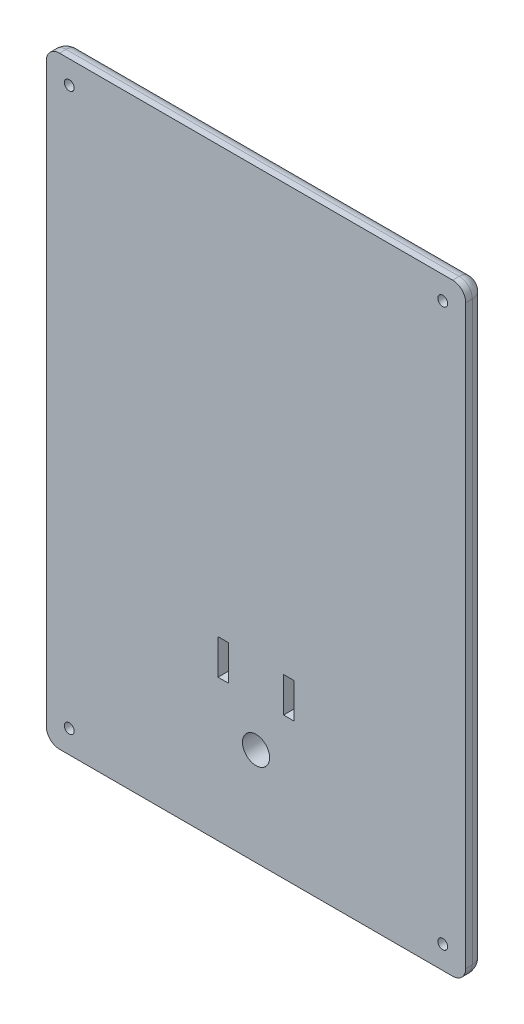
from build123d import *

# Parameters (mm, degrees)
SKETCH1_W           = 81.28
SKETCH1_H           = 116.84
BOSS_EXTRUDE1_DEPTH = 3.81
SKETCH6_R           = 2.6289
SKETCH6_W           = 2.032
SKETCH6_H           = 6.8072
CUT_EXTRUDE5_DEPTH  = 4.81
SKETCH7_R           = 0.9525
CUT_EXTRUDE6_DEPTH  = 4.81
FILLET1_R           = 2.54
CHAMFER1_SIZE       = 0.889
SKETCH2_W           = 38.071387925
SKETCH2_H           = 5.512590528
SKETCH2_H_2         = 5.504700738
CUT_EXTRUDE7_DEPTH  = 1.27
SKETCH10_W          = 0.75982906
SKETCH10_H          = 3.093589743
CUT_EXTRUDE8_DEPTH  = 1.905


with BuildPart() as part:
    # Sketch1 → Boss-Extrude1 (new body)
    with BuildSketch(Plane.XY):
        Rectangle(SKETCH1_W, SKETCH1_H)
    extrude(amount=BOSS_EXTRUDE1_DEPTH)

    # Sketch6 → Cut-Extrude5 (cut, through all)
    with BuildSketch(Plane.XY):
        with Locations((0, -39.497)):
            Circle(SKETCH6_R)
        with Locations((-6.35, -27.559)):
            Rectangle(SKETCH6_W, SKETCH6_H)
        with Locations((6.35, -27.559)):
            Rectangle(SKETCH6_W, SKETCH6_H)
    extrude(amount=CUT_EXTRUDE5_DEPTH, mode=Mode.SUBTRACT)

    # Sketch7 → Cut-Extrude6 (cut, through all)
    with BuildSketch(Plane.XY):
        with Locations((-36.195, 53.975)):
            Circle(SKETCH7_R)
        with Locations((-36.195, -53.975)):
            Circle(SKETCH7_R)
        with Locations((36.195, 53.975)):
            Circle(SKETCH7_R)
        with Locations((36.195, -53.975)):
            Circle(SKETCH7_R)
    extrude(amount=CUT_EXTRUDE6_DEPTH, mode=Mode.SUBTRACT)

    # Fillet1
    fillet1_edges = [part.edges().sort_by_distance(p)[0] for p in [
        (0, 58.42, 0),
        (40.64, 0, 0),
        (0, -58.42, 0),
        (-40.64, 0, 0),
        (-40.64, 58.42, 1.905),
        (40.64, 58.42, 1.905),
        (40.64, -58.42, 1.905),
        (-40.64, -58.42, 1.905),
    ]]
    fillet(fillet1_edges, radius=FILLET1_R)

    # Chamfer1
    chamfer1_edges = [part.edges().sort_by_distance(p)[0] for p in [
        (-37.1475, 53.975, 0),
        (-37.1475, -53.975, 0),
        (35.2425, 53.975, 0),
        (35.2425, -53.975, 0),
    ]]
    chamfer(chamfer1_edges, length=CHAMFER1_SIZE)

    # Sketch2 → Cut-Extrude7 (cut)
    with BuildSketch(Plane.XY):
        with Locations((-10.577370773, 4.552836284)):
            Rectangle(SKETCH2_W, SKETCH2_H)
        with Locations((-10.577370773, -2.752350369)):
            Rectangle(SKETCH2_W, SKETCH2_H_2)
    extrude(amount=CUT_EXTRUDE7_DEPTH, mode=Mode.SUBTRACT)

    # Sketch10 → Cut-Extrude8 (cut)
    with BuildSketch(Plane(origin=(0, 0, 0), x_dir=(-1, 0, 0), z_dir=(0, 0, -1))):
        with BuildLine():
            Line((-18.457038496, 6.289883896), (-19.025214244, 5.770045488))
            add(Edge.make_bspline(
                [(-19.025214244, 5.770045488), (-19.049552457, 5.804377067), (-19.096278431, 5.870288912), (-19.172016362, 5.958546425), (-19.247412298, 6.033836652), (-19.323164735, 6.095845065), (-19.399945115, 6.144194916), (-19.477620158, 6.178427145), (-19.555749502, 6.200188898), (-19.608240361, 6.20289876), (-19.63409512, 6.204233522)],
                knots=[0, 0, 0, 0, 0.000126193, 0.000242273, 0.000348412, 0.000445491, 0.000535382, 0.000619678, 0.000699487, 0.000776955, 0.000776955, 0.000776955, 0.000776955], degree=3))
            add(Edge.make_bspline(
                [(-19.63409512, 6.204233522), (-19.658211698, 6.203387756), (-19.704774473, 6.201754802), (-19.771153162, 6.185523369), (-19.830085109, 6.157510299), (-19.881512796, 6.120880853), (-19.922251112, 6.076750863), (-19.954777498, 6.03046985), (-19.973092587, 5.979386078), (-19.975503213, 5.944299683), (-19.976696616, 5.926929836)],
                knots=[0, 0, 0, 0, 7.2261e-05, 0.000139518, 0.000203249, 0.000267032, 0.000327622, 0.000382659, 0.000435767, 0.000487836, 0.000487836, 0.000487836, 0.000487836], degree=3))
            add(Edge.make_bspline(
                [(-19.976696616, 5.926929836), (-19.975948771, 5.909309509), (-19.974442715, 5.873824617), (-19.959896263, 5.821817089), (-19.937970607, 5.770999681), (-19.917019747, 5.740064706), (-19.906310665, 5.724252219)],
                knots=[0, 0, 0, 0, 5.2748e-05, 0.000106227, 0.000160904, 0.000218074, 0.000218074, 0.000218074, 0.000218074], degree=3))
            add(Edge.make_bspline(
                [(-19.906310665, 5.724252219), (-19.896574951, 5.711961338), (-19.874164622, 5.683669354), (-19.831432716, 5.638859262), (-19.777770415, 5.583962977), (-19.711112683, 5.52086822), (-19.634226664, 5.447305859), (-19.543548594, 5.366167658), (-19.441688581, 5.27494086), (-19.369288843, 5.211413822), (-19.331350729, 5.178125082)],
                knots=[0, 0, 0, 0, 4.7018e-05, 0.000108228, 0.000185584, 0.000277347, 0.000383527, 0.000504803, 0.000642342, 0.000793757, 0.000793757, 0.000793757, 0.000793757], degree=3))
            add(Edge.make_bspline(
                [(-19.331350729, 5.178125082), (-19.295740352, 5.147306097), (-19.228159254, 5.088818066), (-19.132004773, 5.005803696), (-19.047500998, 4.931117692), (-18.973416902, 4.86588093), (-18.910875529, 4.809408928), (-18.859613953, 4.76143175), (-18.819006103, 4.722883424), (-18.795922917, 4.699600211), (-18.786071616, 4.689663544)],
                knots=[0, 0, 0, 0, 0.000141284, 0.000268128, 0.000381091, 0.000479615, 0.000564269, 0.000633869, 0.000690248, 0.000732223, 0.000732223, 0.000732223, 0.000732223], degree=3))
            add(Edge.make_bspline(
                [(-18.786071616, 4.689663544), (-18.748697833, 4.649217106), (-18.676852297, 4.571464849), (-18.583478427, 4.450973302), (-18.506628711, 4.333348985), (-18.447176314, 4.216378603), (-18.402275473, 4.098374507), (-18.370619785, 3.976442654), (-18.351660983, 3.849308931), (-18.349556113, 3.762555686), (-18.348491488, 3.718676631)],
                knots=[0, 0, 0, 0, 0.000165147, 0.000317471, 0.000456725, 0.00058605, 0.000710317, 0.000834757, 0.000963321, 0.001094899, 0.001094899, 0.001094899, 0.001094899], degree=3))
            add(Edge.make_bspline(
                [(-18.348491488, 3.718676631), (-18.349249261, 3.675921874), (-18.35073604, 3.592035449), (-18.368946228, 3.469280161), (-18.394912888, 3.351798023), (-18.4350619, 3.240867406), (-18.483995277, 3.134667418), (-18.545340334, 3.034852318), (-18.617381691, 2.940411936), (-18.699952147, 2.853034509), (-18.791284877, 2.77374555), (-18.889247909, 2.703160646), (-18.994799177, 2.644883816), (-19.107036866, 2.596897005), (-19.225900898, 2.55993692), (-19.35124967, 2.532619973), (-19.483274913, 2.516224772), (-19.573555676, 2.514510849), (-19.619678721, 2.513635232)],
                knots=[0, 0, 0, 0, 0.000128153, 0.00025144, 0.000371573, 0.000488514, 0.000604603, 0.000721827, 0.000839198, 0.000960379, 0.001081798, 0.001201573, 0.001321912, 0.001442728, 0.001567176, 0.001694755, 0.001827183, 0.001965504, 0.001965504, 0.001965504, 0.001965504], degree=3))
            add(Edge.make_bspline(
                [(-19.619678721, 2.513635232), (-19.655884918, 2.514277554), (-19.727593954, 2.51554972), (-19.83328223, 2.525935897), (-19.935336209, 2.542698081), (-20.033640935, 2.566723299), (-20.128639288, 2.597166509), (-20.22033517, 2.634351723), (-20.308095574, 2.678855298), (-20.392584536, 2.729762065), (-20.473391336, 2.788871527), (-20.551537744, 2.85497521), (-20.626247536, 2.929089819), (-20.697879527, 3.011040076), (-20.765975397, 3.101058044), (-20.832764167, 3.197890055), (-20.895277543, 3.303333182), (-20.933894837, 3.377302388), (-20.953619693, 3.415084217)],
                knots=[0, 0, 0, 0, 0.0001086, 0.00021509, 0.000318257, 0.000418629, 0.000518393, 0.000617289, 0.000715135, 0.000813305, 0.000912874, 0.001015159, 0.001120098, 0.001228274, 0.001341404, 0.001458542, 0.001580999, 0.001708851, 0.001708851, 0.001708851, 0.001708851], degree=3))
            Line((-20.953619693, 3.415084217), (-20.285377172, 3.816199334))
            add(Edge.make_bspline(
                [(-20.285377172, 3.816199334), (-20.260704324, 3.773312022), (-20.213404368, 3.69109338), (-20.133250169, 3.580622213), (-20.051136285, 3.486021946), (-19.965164315, 3.408964642), (-19.876379647, 3.348419948), (-19.78435343, 3.30515051), (-19.689021009, 3.278366776), (-19.624084894, 3.275095864), (-19.591693945, 3.273464291)],
                knots=[0, 0, 0, 0, 0.000148344, 0.000284387, 0.000408758, 0.00052348, 0.000629791, 0.000729947, 0.000827455, 0.000924501, 0.000924501, 0.000924501, 0.000924501], degree=3))
            add(Edge.make_bspline(
                [(-19.591693945, 3.273464291), (-19.558747713, 3.274796722), (-19.494827224, 3.277381831), (-19.403588905, 3.301259702), (-19.31993816, 3.338749712), (-19.247631074, 3.392242786), (-19.186405993, 3.453981923), (-19.141218368, 3.522669537), (-19.112831198, 3.596987877), (-19.109829985, 3.648614284), (-19.108320548, 3.674579409)],
                knots=[0, 0, 0, 0, 9.8666e-05, 0.000191427, 0.000280981, 0.000372071, 0.000459628, 0.000540542, 0.000617268, 0.000694903, 0.000694903, 0.000694903, 0.000694903], degree=3))
            add(Edge.make_bspline(
                [(-19.108320548, 3.674579409), (-19.109714452, 3.698735732), (-19.112546034, 3.74780699), (-19.133402598, 3.82076806), (-19.166007769, 3.893695949), (-19.204581985, 3.953513376), (-19.243836081, 4.003596887), (-19.28137185, 4.046991983), (-19.327080487, 4.094935968), (-19.380846096, 4.14748915), (-19.441958291, 4.205114169), (-19.510468554, 4.267805382), (-19.587161397, 4.335010555), (-19.64136805, 4.380790054), (-19.669712107, 4.404727646)],
                knots=[0, 0, 0, 0, 7.2401e-05, 0.000147075, 0.000226032, 0.00031143, 0.000359775, 0.000416896, 0.00048348, 0.000558438, 0.000642422, 0.000735462, 0.000837016, 0.000948314, 0.000948314, 0.000948314, 0.000948314], degree=3))
            add(Edge.make_bspline(
                [(-19.669712107, 4.404727646), (-19.723595288, 4.450317984), (-19.827013421, 4.537819641), (-19.973156364, 4.667056835), (-20.104844241, 4.787840834), (-20.220939654, 4.901664794), (-20.322921838, 5.006426648), (-20.410100126, 5.102977314), (-20.481516825, 5.192061547), (-20.556667501, 5.297575859), (-20.628075669, 5.426152299), (-20.689792589, 5.580844662), (-20.729831923, 5.735517396), (-20.734317773, 5.839356151), (-20.736525676, 5.890464826)],
                knots=[0, 0, 0, 0, 0.000211741, 0.000406395, 0.000585234, 0.000747747, 0.00089408, 0.001023802, 0.001137832, 0.001236415, 0.001412187, 0.001577378, 0.00173534, 0.001888445, 0.001888445, 0.001888445, 0.001888445], degree=3))
            add(Edge.make_bspline(
                [(-20.736525676, 5.890464826), (-20.735607412, 5.926708355), (-20.733798334, 5.998112), (-20.717661076, 6.103100657), (-20.693543329, 6.204405889), (-20.658517437, 6.301658089), (-20.613058059, 6.394735444), (-20.557849409, 6.484093608), (-20.492034203, 6.568910148), (-20.417864908, 6.649128837), (-20.336149335, 6.72243959), (-20.248825861, 6.787143675), (-20.156388744, 6.841793686), (-20.059403468, 6.887129838), (-19.957269055, 6.921831783), (-19.850737926, 6.946430251), (-19.739657279, 6.961060635), (-19.664102621, 6.963049466), (-19.625614885, 6.964062582)],
                knots=[0, 0, 0, 0, 0.000108666, 0.000214084, 0.000317952, 0.000420689, 0.000523472, 0.000628195, 0.000735224, 0.000845039, 0.000955536, 0.001064086, 0.001170546, 0.001277158, 0.001384697, 0.001493515, 0.001604697, 0.00172014, 0.00172014, 0.00172014, 0.00172014], degree=3))
            add(Edge.make_bspline(
                [(-19.625614885, 6.964062582), (-19.575736684, 6.962237931), (-19.476374004, 6.958603033), (-19.329463414, 6.930179314), (-19.185967293, 6.885480022), (-19.070335429, 6.831555244), (-18.978329314, 6.779318286), (-18.907815221, 6.731225075), (-18.836063335, 6.676131717), (-18.762495024, 6.613864599), (-18.688477298, 6.543250525), (-18.611905482, 6.46597052), (-18.533822958, 6.381356704), (-18.483081698, 6.320908986), (-18.457038496, 6.289883896)],
                knots=[0, 0, 0, 0, 0.000149543, 0.000297906, 0.000447296, 0.000599454, 0.000679604, 0.000764513, 0.000855255, 0.000950917, 0.001053499, 0.001162036, 0.001277268, 0.001398775, 0.001398775, 0.001398775, 0.001398775], degree=3))
        make_face()
        Polygon((-17.968576958, 1.86235318), (-16.020666969, 6.964062582), (-15.444859009, 6.964062582), (-17.392768998, 1.86235318), align=None)
        Polygon((-14.874987214, 6.855515574), (-14.190632246, 6.855515574), (-12.269859009, 4.069758362), (-12.269859009, 6.855515574), (-11.510029949, 6.855515574), (-11.510029949, 2.62218224), (-12.199473058, 2.62218224), (-14.115158154, 5.399459217), (-14.115158154, 2.62218224), (-14.874987214, 2.62218224), align=None)
        with BuildLine():
            add(Edge.make_bspline(
                [(-10.234602599, 5.770045488), (-10.203900167, 5.768457699), (-10.143373019, 5.765327514), (-10.056460869, 5.739217177), (-9.977251147, 5.695225129), (-9.907087465, 5.636251514), (-9.847818666, 5.565938911), (-9.804323015, 5.486178341), (-9.777873854, 5.398849173), (-9.77482918, 5.33801949), (-9.773277813, 5.307024655)],
                knots=[0, 0, 0, 0, 9.1978e-05, 0.000181327, 0.000269379, 0.000362105, 0.00045483, 0.000543626, 0.000632975, 0.000725798, 0.000725798, 0.000725798, 0.000725798], degree=3))
            add(Edge.make_bspline(
                [(-9.773277813, 5.307024655), (-9.774808913, 5.276582237), (-9.777813831, 5.216836345), (-9.804714785, 5.130822537), (-9.847781664, 5.051491801), (-9.907097577, 4.981192811), (-9.977248591, 4.922215536), (-10.056461545, 4.878224422), (-10.143372843, 4.852113839), (-10.203900108, 4.848983687), (-10.234602599, 4.847395915)],
                knots=[0, 0, 0, 0, 9.1134e-05, 0.000178858, 0.000267654, 0.00036038, 0.000453106, 0.000541157, 0.000630506, 0.000722485, 0.000722485, 0.000722485, 0.000722485], degree=3))
            add(Edge.make_bspline(
                [(-10.234602599, 4.847395915), (-10.265320939, 4.848953623), (-10.32587945, 4.852024507), (-10.412672804, 4.878601514), (-10.492678222, 4.920952215), (-10.562799548, 4.979563839), (-10.622657842, 5.048794947), (-10.664462323, 5.128779592), (-10.691516568, 5.21540277), (-10.694434127, 5.276006561), (-10.695927385, 5.307024655)],
                knots=[0, 0, 0, 0, 9.1978e-05, 0.000181327, 0.000269721, 0.000361906, 0.000453982, 0.000542376, 0.000630913, 0.000723735, 0.000723735, 0.000723735, 0.000723735], degree=3))
            add(Edge.make_bspline(
                [(-10.695927385, 5.307024655), (-10.694396688, 5.338030788), (-10.691392582, 5.398882645), (-10.664688146, 5.485921351), (-10.622411939, 5.566190848), (-10.562876564, 5.636179344), (-10.492695641, 5.695518905), (-10.412901025, 5.738997043), (-10.325853802, 5.765365886), (-10.265312308, 5.768470613), (-10.234602599, 5.770045488)],
                knots=[0, 0, 0, 0, 9.2823e-05, 0.000182172, 0.000270566, 0.000363291, 0.000456017, 0.000544813, 0.000634162, 0.00072614, 0.00072614, 0.00072614, 0.00072614], degree=3))
        make_face()
        with BuildLine():
            add(Edge.make_bspline(
                [(-10.234602599, 3.490558309), (-10.203929201, 3.48887656), (-10.143538577, 3.485565487), (-10.05628236, 3.460855297), (-9.977533122, 3.416459921), (-9.907120781, 3.358553846), (-9.847581878, 3.288885108), (-9.804548506, 3.20943643), (-9.777750546, 3.122516423), (-9.774792032, 3.061935803), (-9.773277813, 3.030929569)],
                knots=[0, 0, 0, 0, 9.1978e-05, 0.000181089, 0.000269141, 0.000361326, 0.000453402, 0.000542198, 0.000630734, 0.000723557, 0.000723557, 0.000723557, 0.000723557], degree=3))
            add(Edge.make_bspline(
                [(-9.773277813, 3.030929569), (-9.774782113, 2.999918356), (-9.777721245, 2.939328006), (-9.804733945, 2.85223863), (-9.847517573, 2.772136956), (-9.907125558, 2.701721671), (-9.97724152, 2.642724303), (-10.056463418, 2.598738316), (-10.143372356, 2.57262638), (-10.203899944, 2.569496413), (-10.234602599, 2.567908736)],
                knots=[0, 0, 0, 0, 9.2823e-05, 0.000181359, 0.000270901, 0.000363627, 0.000456353, 0.000544404, 0.000633753, 0.000725731, 0.000725731, 0.000725731, 0.000725731], degree=3))
            add(Edge.make_bspline(
                [(-10.234602599, 2.567908736), (-10.265312529, 2.569483503), (-10.325854459, 2.572588018), (-10.41289849, 2.598958414), (-10.492705266, 2.642430635), (-10.562838845, 2.701793235), (-10.622713132, 2.771887609), (-10.664280382, 2.852491365), (-10.691544698, 2.939295172), (-10.69444365, 2.99990724), (-10.695927385, 3.030929569)],
                knots=[0, 0, 0, 0, 9.1978e-05, 0.000181327, 0.000270123, 0.000362849, 0.000455575, 0.000544718, 0.000633254, 0.000726077, 0.000726077, 0.000726077, 0.000726077], degree=3))
            add(Edge.make_bspline(
                [(-10.695927385, 3.030929569), (-10.694433861, 3.061947112), (-10.691515783, 3.122549828), (-10.664465293, 3.209180783), (-10.622646513, 3.289135809), (-10.562843839, 3.358482134), (-10.492412162, 3.416751296), (-10.413080564, 3.460638215), (-10.325688321, 3.485604133), (-10.265283307, 3.488889577), (-10.234602599, 3.490558309)],
                knots=[0, 0, 0, 0, 9.2823e-05, 0.000181359, 0.000269753, 0.000361829, 0.000454014, 0.00054281, 0.000631921, 0.000723899, 0.000723899, 0.000723899, 0.000723899], degree=3))
        make_face()
        Polygon((-36.207374758, -0.250875626), (-34.144981596, -0.250875626), (-34.144981596, -1.010704686), (-35.447545698, -1.010704686), (-35.447545698, -1.82480725), (-34.144981596, -1.82480725), (-34.144981596, -2.58463631), (-35.447545698, -2.58463631), (-35.447545698, -4.484208959), (-36.207374758, -4.484208959), align=None)
        with BuildLine():
            add(Edge.make_bspline(
                [(-33.169754566, -0.088055113), (-33.137005938, -0.089661885), (-33.072700854, -0.092816935), (-32.98057507, -0.123571663), (-32.89602227, -0.171840288), (-32.821275251, -0.238065992), (-32.75910767, -0.317151597), (-32.711609329, -0.405693189), (-32.685149982, -0.503794421), (-32.68147517, -0.571561726), (-32.67959698, -0.606197474)],
                knots=[0, 0, 0, 0, 9.7968e-05, 0.000192369, 0.000288087, 0.000388444, 0.000489896, 0.000588518, 0.000687886, 0.000791764, 0.000791764, 0.000791764, 0.000791764], degree=3))
            add(Edge.make_bspline(
                [(-32.67959698, -0.606197474), (-32.681407972, -0.640577976), (-32.684936774, -0.707570021), (-32.712218307, -0.804339483), (-32.75781023, -0.89283807), (-32.820481329, -0.970749107), (-32.894417993, -1.035908207), (-32.977123249, -1.08505312), (-33.068366201, -1.114096969), (-33.131673465, -1.117515764), (-33.163818401, -1.119251694)],
                knots=[0, 0, 0, 0, 0.000103034, 0.000200767, 0.000298998, 0.000399785, 0.000498946, 0.000593194, 0.000686531, 0.000782811, 0.000782811, 0.000782811, 0.000782811], degree=3))
            add(Edge.make_bspline(
                [(-33.163818401, -1.119251694), (-33.196852897, -1.117650666), (-33.261717433, -1.114506985), (-33.354598838, -1.083680299), (-33.440279356, -1.035791821), (-33.514702123, -0.968213022), (-33.577581662, -0.888565455), (-33.623005257, -0.797962538), (-33.651418839, -0.699190492), (-33.654791506, -0.630419507), (-33.656520057, -0.595173168)],
                knots=[0, 0, 0, 0, 9.8812e-05, 0.000194021, 0.000290476, 0.000391395, 0.000493514, 0.000593257, 0.000693668, 0.000799236, 0.000799236, 0.000799236, 0.000799236], degree=3))
            add(Edge.make_bspline(
                [(-33.656520057, -0.595173168), (-33.654638921, -0.561376468), (-33.6509437, -0.494987729), (-33.624325859, -0.399067575), (-33.577916653, -0.312014505), (-33.516196871, -0.234376637), (-33.442106382, -0.169386291), (-33.357604341, -0.122583616), (-33.266098567, -0.093099146), (-33.202200832, -0.089753818), (-33.169754566, -0.088055113)],
                knots=[0, 0, 0, 0, 0.000101345, 0.000199078, 0.000295804, 0.000395399, 0.0004952, 0.000589346, 0.000683492, 0.000780615, 0.000780615, 0.000780615, 0.000780615], degree=3))
        make_face()
        with Locations((-33.168058519, -2.937414088)):
            Rectangle(SKETCH10_W, SKETCH10_H)
        with BuildLine():
            Line((-32.191135442, -1.390619216), (-31.53985339, -1.390619216))
            Line((-31.53985339, -1.390619216), (-31.53985339, -1.771381769))
            add(Edge.make_bspline(
                [(-31.53985339, -1.771381769), (-31.521429872, -1.737543296), (-31.485420339, -1.671404597), (-31.419267809, -1.582626491), (-31.343269102, -1.507860047), (-31.260155089, -1.445541457), (-31.169673865, -1.396970235), (-31.074248358, -1.362357117), (-30.974694931, -1.339863386), (-30.906782958, -1.337526712), (-30.872458893, -1.336345711)],
                knots=[0, 0, 0, 0, 0.000115493, 0.000225736, 0.000330676, 0.000434305, 0.000536367, 0.00063751, 0.000738139, 0.000840974, 0.000840974, 0.000840974, 0.000840974], degree=3))
            add(Edge.make_bspline(
                [(-30.872458893, -1.336345711), (-30.847535338, -1.337512787), (-30.796782082, -1.339889371), (-30.719426977, -1.353704486), (-30.640955775, -1.378684843), (-30.589314961, -1.401176333), (-30.562930314, -1.412667827)],
                knots=[0, 0, 0, 0, 7.4799e-05, 0.000152318, 0.00023493, 0.000321233, 0.000321233, 0.000321233, 0.000321233], degree=3))
            Line((-30.562930314, -1.412667827), (-30.798680848, -2.056317666))
            add(Edge.make_bspline(
                [(-30.798680848, -2.056317666), (-30.819753579, -2.046136341), (-30.859362202, -2.02699937), (-30.916867044, -2.004415772), (-30.969055074, -1.990636365), (-31.002141326, -1.988580356), (-31.017470912, -1.987627763)],
                knots=[0, 0, 0, 0, 7.0186e-05, 0.000131923, 0.000185194, 0.000231183, 0.000231183, 0.000231183, 0.000231183], degree=3))
            add(Edge.make_bspline(
                [(-31.017470912, -1.987627763), (-31.031945022, -1.988259001), (-31.06041809, -1.989500757), (-31.102443542, -2.000142182), (-31.142022767, -2.01849299), (-31.181063085, -2.042002195), (-31.216484647, -2.074681749), (-31.251884331, -2.112514135), (-31.283080427, -2.159223248), (-31.316001356, -2.211212863), (-31.34403235, -2.274848105), (-31.368068065, -2.35081547), (-31.389484079, -2.439993953), (-31.404221221, -2.542857047), (-31.41846526, -2.658409376), (-31.426943662, -2.787499078), (-31.433262722, -2.92971796), (-31.43364909, -3.028991873), (-31.433850452, -3.08073006)],
                knots=[0, 0, 0, 0, 4.3382e-05, 8.534e-05, 0.000128995, 0.00017394, 0.000221406, 0.000273031, 0.000329027, 0.000389528, 0.000457466, 0.000536845, 0.000628377, 0.000732245, 0.000848372, 0.000977608, 0.0011202, 0.001275397, 0.001275397, 0.001275397, 0.001275397], degree=3))
            Line((-31.433850452, -3.08073006), (-31.431306382, -3.231678243))
            Line((-31.431306382, -3.231678243), (-31.431306382, -4.484208959))
            Line((-31.431306382, -4.484208959), (-32.191135442, -4.484208959))
            Line((-32.191135442, -4.484208959), (-32.191135442, -1.390619216))
        make_face()
        with BuildLine():
            Line((-30.183015784, -1.390619216), (-29.423186724, -1.390619216))
            Line((-29.423186724, -1.390619216), (-29.423186724, -1.760357463))
            add(Edge.make_bspline(
                [(-29.423186724, -1.760357463), (-29.389389913, -1.726246769), (-29.322846771, -1.659085616), (-29.212571768, -1.572743916), (-29.097543773, -1.498911096), (-28.976368829, -1.439138781), (-28.849343327, -1.393498301), (-28.717069299, -1.360053631), (-28.578867332, -1.340322323), (-28.484770472, -1.337685942), (-28.436935388, -1.336345711)],
                knots=[0, 0, 0, 0, 0.000143934, 0.000283395, 0.000419134, 0.00055339, 0.000687788, 0.000823328, 0.000962086, 0.001105562, 0.001105562, 0.001105562, 0.001105562], degree=3))
            add(Edge.make_bspline(
                [(-28.436935388, -1.336345711), (-28.389037146, -1.337852324), (-28.294751004, -1.340818043), (-28.15718818, -1.367957152), (-28.026869382, -1.412049032), (-27.905228425, -1.474896591), (-27.791386158, -1.552510058), (-27.690385869, -1.648899191), (-27.599473472, -1.760226948), (-27.551013664, -1.844391929), (-27.526158145, -1.887560989)],
                knots=[0, 0, 0, 0, 0.000143567, 0.000282606, 0.00041884, 0.000554995, 0.000692136, 0.000830717, 0.000972429, 0.001121652, 0.001121652, 0.001121652, 0.001121652], degree=3))
            add(Edge.make_bspline(
                [(-27.526158145, -1.887560989), (-27.494141024, -1.844274493), (-27.4313004, -1.759315248), (-27.31990967, -1.648391322), (-27.199463058, -1.552500007), (-27.067630199, -1.474323593), (-26.927912116, -1.412263552), (-26.780920198, -1.368120977), (-26.627987124, -1.3408634), (-26.523907774, -1.337864118), (-26.471216905, -1.336345711)],
                knots=[0, 0, 0, 0, 0.000161323, 0.000316632, 0.00047, 0.000622125, 0.000775131, 0.000927512, 0.001081567, 0.001239528, 0.001239528, 0.001239528, 0.001239528], degree=3))
            add(Edge.make_bspline(
                [(-26.471216905, -1.336345711), (-26.416793495, -1.337922343), (-26.310808963, -1.340992685), (-26.157222157, -1.371199484), (-26.013369528, -1.41787352), (-25.882430178, -1.485795666), (-25.764030656, -1.566252137), (-25.66313998, -1.661314816), (-25.579409938, -1.767666558), (-25.524890943, -1.866973136), (-25.489645878, -1.954771523), (-25.468364594, -2.03117257), (-25.44846001, -2.116484003), (-25.434160558, -2.211852526), (-25.42081265, -2.31638175), (-25.413063665, -2.430766619), (-25.407796599, -2.554621798), (-25.40723717, -2.640316522), (-25.406947408, -2.684703083)],
                knots=[0, 0, 0, 0, 0.000163088, 0.000317598, 0.000467772, 0.000615304, 0.00075856, 0.000895942, 0.001029449, 0.001163049, 0.001234228, 0.001312856, 0.0014007, 0.001496897, 0.001601977, 0.001716773, 0.001840689, 0.00197384, 0.00197384, 0.00197384, 0.00197384], degree=3))
            Line((-25.406947408, -2.684703083), (-25.406947408, -4.484208959))
            Line((-25.406947408, -4.484208959), (-26.166776467, -4.484208959))
            Line((-26.166776467, -4.484208959), (-26.166776467, -2.930629899))
            add(Edge.make_bspline(
                [(-26.166776467, -2.930629899), (-26.167408881, -2.889074547), (-26.168622742, -2.809312804), (-26.173783333, -2.694909812), (-26.185334944, -2.59115617), (-26.198874912, -2.497477181), (-26.218250867, -2.414369541), (-26.241876326, -2.34163291), (-26.269281715, -2.279162584), (-26.302372896, -2.226965075), (-26.339435058, -2.183006528), (-26.380661366, -2.145325348), (-26.425621974, -2.113175845), (-26.474724516, -2.085772962), (-26.529255351, -2.06723985), (-26.587373605, -2.052698109), (-26.649534072, -2.04279508), (-26.692511804, -2.04220469), (-26.714599651, -2.041901267)],
                knots=[0, 0, 0, 0, 0.000124685, 0.000239322, 0.000343367, 0.000437757, 0.000523121, 0.000599014, 0.000666951, 0.000727178, 0.000783749, 0.000838968, 0.000894272, 0.000949295, 0.001006967, 0.001066408, 0.001129012, 0.001195207, 0.001195207, 0.001195207, 0.001195207], degree=3))
            add(Edge.make_bspline(
                [(-26.714599651, -2.041901267), (-26.748636711, -2.043078016), (-26.815427668, -2.045387153), (-26.912755704, -2.067453538), (-27.004342104, -2.103529715), (-27.089843747, -2.152608159), (-27.167420826, -2.213906209), (-27.235281133, -2.286611541), (-27.291324283, -2.371143161), (-27.330118717, -2.449571549), (-27.354360366, -2.520486571), (-27.371460645, -2.581219592), (-27.384789634, -2.649899656), (-27.395222329, -2.725831192), (-27.405231282, -2.809443448), (-27.410141618, -2.900630695), (-27.41516639, -2.999266252), (-27.415100978, -3.067436111), (-27.415067066, -3.102778671)],
                knots=[0, 0, 0, 0, 0.000101989, 0.000200133, 0.000297611, 0.000396379, 0.000494783, 0.00059319, 0.000693386, 0.000798065, 0.000854654, 0.000918024, 0.000987209, 0.001064323, 0.001147951, 0.00123973, 0.001338192, 0.001444199, 0.001444199, 0.001444199, 0.001444199], degree=3))
            Line((-27.415067066, -3.102778671), (-27.415067066, -4.484208959))
            Line((-27.415067066, -4.484208959), (-28.174896126, -4.484208959))
            Line((-28.174896126, -4.484208959), (-28.174896126, -3.00101585))
            add(Edge.make_bspline(
                [(-28.174896126, -3.00101585), (-28.174959921, -2.967938691), (-28.175082643, -2.904308951), (-28.178771415, -2.812426389), (-28.183656071, -2.727585443), (-28.19050379, -2.649549477), (-28.198401284, -2.578415549), (-28.209799189, -2.51457281), (-28.22177374, -2.457669469), (-28.242304269, -2.39302897), (-28.271234425, -2.32139648), (-28.314456501, -2.245434213), (-28.366717893, -2.181833716), (-28.426697699, -2.130100043), (-28.494477454, -2.090683135), (-28.568340085, -2.061361854), (-28.649695953, -2.045535127), (-28.705695893, -2.043138115), (-28.734591638, -2.041901267)],
                knots=[0, 0, 0, 0, 9.9222e-05, 0.000190872, 0.000275827, 0.000354139, 0.000425876, 0.000490426, 0.00054865, 0.00060015, 0.000693694, 0.000779947, 0.000861273, 0.000939457, 0.001016249, 0.001095461, 0.001176787, 0.001263489, 0.001263489, 0.001263489, 0.001263489], degree=3))
            add(Edge.make_bspline(
                [(-28.734591638, -2.041901267), (-28.767241344, -2.043009454), (-28.831904359, -2.045204229), (-28.926095918, -2.068777905), (-29.016151785, -2.104192152), (-29.10009082, -2.154639468), (-29.176499196, -2.217380048), (-29.243680077, -2.292153421), (-29.299428699, -2.378870895), (-29.338395334, -2.459462619), (-29.36228351, -2.532146873), (-29.379843592, -2.594456884), (-29.392676657, -2.664649437), (-29.403383868, -2.741936395), (-29.413333564, -2.826408985), (-29.418264218, -2.918438685), (-29.423284025, -3.017923489), (-29.423219939, -3.086658138), (-29.423186724, -3.122283211)],
                knots=[0, 0, 0, 0, 9.7758e-05, 0.000193611, 0.000289513, 0.000387246, 0.000486054, 0.000585142, 0.000687458, 0.00079443, 0.000852624, 0.000916811, 0.000988492, 0.001066446, 0.001150917, 0.001243542, 0.001342851, 0.001449706, 0.001449706, 0.001449706, 0.001449706], degree=3))
            Line((-29.423186724, -3.122283211), (-29.423186724, -4.484208959))
            Line((-29.423186724, -4.484208959), (-30.183015784, -4.484208959))
            Line((-30.183015784, -4.484208959), (-30.183015784, -1.390619216))
        make_face()
        Polygon((-24.999896126, -1.390619216), (-24.241763113, -1.390619216), (-23.588785014, -3.150267987), (-22.897645858, -1.390619216), (-22.432080955, -1.390619216), (-21.743485869, -3.130763446), (-21.093051841, -1.390619216), (-20.332374758, -1.390619216), (-21.489078818, -4.484208959), (-21.968212098, -4.484208959), (-22.666135442, -2.721168094), (-23.358970645, -4.484208959), (-23.852520324, -4.484208959), align=None)
        with BuildLine():
            Line((-17.645836296, -1.390619216), (-16.886007237, -1.390619216))
            Line((-16.886007237, -1.390619216), (-16.886007237, -4.484208959))
            Line((-16.886007237, -4.484208959), (-17.645836296, -4.484208959))
            Line((-17.645836296, -4.484208959), (-17.645836296, -4.146695604))
            add(Edge.make_bspline(
                [(-17.645836296, -4.146695604), (-17.683485546, -4.179548794), (-17.756555306, -4.243310347), (-17.871689602, -4.326042584), (-17.987160334, -4.394285986), (-18.103522342, -4.448638135), (-18.222564061, -4.488771602), (-18.345142544, -4.51782917), (-18.473023051, -4.534965128), (-18.559954458, -4.537297806), (-18.604102856, -4.538482463)],
                knots=[0, 0, 0, 0, 0.000149841, 0.000290812, 0.000424617, 0.000551722, 0.00067535, 0.000800823, 0.000929153, 0.001061577, 0.001061577, 0.001061577, 0.001061577], degree=3))
            add(Edge.make_bspline(
                [(-18.604102856, -4.538482463), (-18.653661396, -4.537367551), (-18.75159188, -4.535164422), (-18.895293993, -4.511972928), (-19.03405267, -4.476473178), (-19.167755277, -4.426236595), (-19.296158554, -4.361139831), (-19.420245175, -4.282881353), (-19.537887919, -4.18871382), (-19.65006612, -4.082711621), (-19.752775809, -3.966108447), (-19.842565588, -3.840522736), (-19.918251698, -3.707735642), (-19.980257279, -3.568187417), (-20.029032675, -3.42198048), (-20.063802553, -3.268651109), (-20.084316821, -3.108144541), (-20.086855909, -2.998813752), (-20.088143989, -2.943350252)],
                knots=[0, 0, 0, 0, 0.000148559, 0.000293561, 0.000435483, 0.000577713, 0.00072107, 0.000866695, 0.001017016, 0.00117238, 0.001329218, 0.001482413, 0.00163472, 0.001786951, 0.001939807, 0.002096361, 0.002257925, 0.002424276, 0.002424276, 0.002424276, 0.002424276], degree=3))
            add(Edge.make_bspline(
                [(-20.088143989, -2.943350252), (-20.086792145, -2.885917724), (-20.084140352, -2.773257422), (-20.064742646, -2.607933785), (-20.030614403, -2.450802624), (-19.984078091, -2.301646291), (-19.924217205, -2.160439015), (-19.851310647, -2.026949456), (-19.764366589, -1.901526533), (-19.664178976, -1.786305033), (-19.556000961, -1.680698963), (-19.440269609, -1.588760504), (-19.318794705, -1.510654505), (-19.191447161, -1.446889699), (-19.058245164, -1.397615484), (-18.919714591, -1.36159201), (-18.775240466, -1.33997666), (-18.676823521, -1.337566079), (-18.626999491, -1.336345711)],
                knots=[0, 0, 0, 0, 0.000172282, 0.000337951, 0.000498461, 0.000654022, 0.000806017, 0.000957822, 0.001109552, 0.001262885, 0.001415213, 0.001562486, 0.001705511, 0.001847729, 0.001988868, 0.00213079, 0.002276504, 0.002425911, 0.002425911, 0.002425911, 0.002425911], degree=3))
            add(Edge.make_bspline(
                [(-18.626999491, -1.336345711), (-18.580846295, -1.337304554), (-18.489525756, -1.339201757), (-18.355297722, -1.359801754), (-18.225115888, -1.390957787), (-18.099690403, -1.435349525), (-17.977992486, -1.491403126), (-17.862115418, -1.561642467), (-17.749524283, -1.643115418), (-17.680825987, -1.706747519), (-17.645836296, -1.739156876)],
                knots=[0, 0, 0, 0, 0.000138355, 0.000273755, 0.000406419, 0.000539448, 0.000672238, 0.000807638, 0.000945366, 0.001088328, 0.001088328, 0.001088328, 0.001088328], degree=3))
            Line((-17.645836296, -1.739156876), (-17.645836296, -1.390619216))
        make_face()
        with BuildLine():
            add(Edge.make_bspline(
                [(-18.467571072, -2.041901267), (-18.49784802, -2.042830268), (-18.557188862, -2.04465105), (-18.64445769, -2.05560318), (-18.727860511, -2.074901321), (-18.806802501, -2.10341018), (-18.882460186, -2.138138124), (-18.953684693, -2.181634302), (-19.021063859, -2.23304586), (-19.084201419, -2.291128126), (-19.141760609, -2.354971155), (-19.191379989, -2.424637733), (-19.233548446, -2.49825074), (-19.269212002, -2.576031506), (-19.294739016, -2.658900417), (-19.314956401, -2.745778668), (-19.325447914, -2.83737601), (-19.327349695, -2.899796764), (-19.328314929, -2.931477923)],
                knots=[0, 0, 0, 0, 9.0838e-05, 0.000178036, 0.0002634, 0.000347084, 0.000429412, 0.000512748, 0.000596873, 0.000683297, 0.000769778, 0.000854262, 0.000939357, 0.001023998, 0.001110355, 0.001199025, 0.001291272, 0.001386346, 0.001386346, 0.001386346, 0.001386346], degree=3))
            add(Edge.make_bspline(
                [(-19.328314929, -2.931477923), (-19.327364439, -2.963446448), (-19.325491511, -3.026440057), (-19.314786763, -3.118810056), (-19.295296883, -3.206957394), (-19.266861884, -3.290169461), (-19.232136153, -3.369569064), (-19.18986713, -3.444789764), (-19.137947039, -3.514501567), (-19.080337392, -3.580354087), (-19.015904575, -3.639157832), (-18.94814415, -3.691370158), (-18.876130566, -3.735056178), (-18.800645117, -3.770363496), (-18.721941892, -3.799135992), (-18.639034192, -3.818191595), (-18.5527342, -3.830373481), (-18.493901217, -3.832069888), (-18.464178978, -3.832926908)],
                knots=[0, 0, 0, 0, 9.592e-05, 0.00018901, 0.000278508, 0.000366199, 0.000452389, 0.00053822, 0.000624385, 0.000712698, 0.00080032, 0.000885634, 0.000968969, 0.001052425, 0.00113531, 0.001219849, 0.001307159, 0.001396302, 0.001396302, 0.001396302, 0.001396302], degree=3))
            add(Edge.make_bspline(
                [(-18.464178978, -3.832926908), (-18.433338086, -3.831992698), (-18.372873173, -3.83016114), (-18.284180598, -3.81930896), (-18.199657378, -3.799940061), (-18.119655177, -3.771267982), (-18.042952035, -3.736789316), (-17.970240131, -3.694143086), (-17.902308498, -3.642849503), (-17.838813093, -3.584242173), (-17.780631794, -3.519877827), (-17.730326217, -3.449297683), (-17.686508218, -3.374759088), (-17.652047379, -3.294499677), (-17.624680639, -3.209923616), (-17.605045635, -3.120506008), (-17.594365331, -3.02615045), (-17.592508783, -2.961749104), (-17.591562792, -2.928933852)],
                knots=[0, 0, 0, 0, 9.2532e-05, 0.000181413, 0.000267603, 0.000352087, 0.000435955, 0.000519583, 0.000604386, 0.000690809, 0.000778488, 0.000864156, 0.000950408, 0.001037375, 0.001125606, 0.00121676, 0.001311534, 0.001409996, 0.001409996, 0.001409996, 0.001409996], degree=3))
            add(Edge.make_bspline(
                [(-17.591562792, -2.928933852), (-17.592497028, -2.896683007), (-17.594321863, -2.833687737), (-17.605091697, -2.741302278), (-17.624866098, -2.653640424), (-17.651669585, -2.570541039), (-17.686743493, -2.492194132), (-17.730594646, -2.41946838), (-17.7803484, -2.349844111), (-17.839173849, -2.287218602), (-17.902325285, -2.229035633), (-17.971255963, -2.179293206), (-18.043794193, -2.136423801), (-18.120385651, -2.101226367), (-18.201739538, -2.075425313), (-18.286407202, -2.055448501), (-18.375709633, -2.044657623), (-18.436450901, -2.042835046), (-18.467571072, -2.041901267)],
                knots=[0, 0, 0, 0, 9.6768e-05, 0.000189015, 0.000278513, 0.000365937, 0.000450579, 0.000535368, 0.000620348, 0.000706772, 0.000792624, 0.000877604, 0.000961232, 0.001045101, 0.001129844, 0.00121686, 0.001305741, 0.00139912, 0.00139912, 0.00139912, 0.00139912], degree=3))
        make_face(mode=Mode.SUBTRACT)
        with BuildLine():
            Line((-16.234725185, -1.390619216), (-15.583443134, -1.390619216))
            Line((-15.583443134, -1.390619216), (-15.583443134, -1.771381769))
            add(Edge.make_bspline(
                [(-15.583443134, -1.771381769), (-15.565019615, -1.737543296), (-15.529010083, -1.671404597), (-15.462857552, -1.582626491), (-15.386858846, -1.507860047), (-15.303744832, -1.445541457), (-15.213263609, -1.396970235), (-15.117838102, -1.362357117), (-15.018284675, -1.339863386), (-14.950372701, -1.337526712), (-14.916048636, -1.336345711)],
                knots=[0, 0, 0, 0, 0.000115493, 0.000225736, 0.000330676, 0.000434305, 0.000536367, 0.00063751, 0.000738139, 0.000840974, 0.000840974, 0.000840974, 0.000840974], degree=3))
            add(Edge.make_bspline(
                [(-14.916048636, -1.336345711), (-14.891125082, -1.337512787), (-14.840371826, -1.339889371), (-14.763016721, -1.353704486), (-14.684545518, -1.378684843), (-14.632904705, -1.401176333), (-14.606520057, -1.412667827)],
                knots=[0, 0, 0, 0, 7.4799e-05, 0.000152318, 0.00023493, 0.000321233, 0.000321233, 0.000321233, 0.000321233], degree=3))
            Line((-14.606520057, -1.412667827), (-14.842270591, -2.056317666))
            add(Edge.make_bspline(
                [(-14.842270591, -2.056317666), (-14.863343323, -2.046136341), (-14.902951945, -2.02699937), (-14.960456788, -2.004415772), (-15.012644817, -1.990636365), (-15.04573107, -1.988580356), (-15.061060655, -1.987627763)],
                knots=[0, 0, 0, 0, 7.0186e-05, 0.000131923, 0.000185194, 0.000231183, 0.000231183, 0.000231183, 0.000231183], degree=3))
            add(Edge.make_bspline(
                [(-15.061060655, -1.987627763), (-15.075534765, -1.988259001), (-15.104007834, -1.989500757), (-15.146033286, -2.000142182), (-15.18561251, -2.01849299), (-15.224652828, -2.042002195), (-15.260074391, -2.074681749), (-15.295474074, -2.112514135), (-15.326670171, -2.159223248), (-15.3595911, -2.211212863), (-15.387622094, -2.274848105), (-15.411657808, -2.35081547), (-15.433073823, -2.439993953), (-15.447810964, -2.542857047), (-15.462055004, -2.658409376), (-15.470533406, -2.787499078), (-15.476852466, -2.92971796), (-15.477238834, -3.028991873), (-15.477440196, -3.08073006)],
                knots=[0, 0, 0, 0, 4.3382e-05, 8.534e-05, 0.000128995, 0.00017394, 0.000221406, 0.000273031, 0.000329027, 0.000389528, 0.000457466, 0.000536845, 0.000628377, 0.000732245, 0.000848372, 0.000977608, 0.0011202, 0.001275397, 0.001275397, 0.001275397, 0.001275397], degree=3))
            Line((-15.477440196, -3.08073006), (-15.474896126, -3.231678243))
            Line((-15.474896126, -3.231678243), (-15.474896126, -4.484208959))
            Line((-15.474896126, -4.484208959), (-16.234725185, -4.484208959))
            Line((-16.234725185, -4.484208959), (-16.234725185, -1.390619216))
        make_face()
        with BuildLine():
            Line((-11.135559854, -3.127371352), (-13.575323476, -3.127371352))
            add(Edge.make_bspline(
                [(-13.575323476, -3.127371352), (-13.570348995, -3.155720021), (-13.560573747, -3.211427393), (-13.539346449, -3.292347184), (-13.512257234, -3.368604629), (-13.479792515, -3.440301666), (-13.442499647, -3.507817329), (-13.399000607, -3.570834942), (-13.34984714, -3.629298846), (-13.295323438, -3.682954948), (-13.236338312, -3.731031979), (-13.173177818, -3.773150497), (-13.105776779, -3.807685106), (-13.034907922, -3.836794197), (-12.960041694, -3.859851547), (-12.881067911, -3.875753762), (-12.798195919, -3.885147259), (-12.741740987, -3.886505921), (-12.712883572, -3.887200412)],
                knots=[0, 0, 0, 0, 8.6319e-05, 0.000169625, 0.000250627, 0.000328811, 0.000405495, 0.000481709, 0.000558149, 0.000634306, 0.000710859, 0.000786123, 0.000861602, 0.000937664, 0.001015724, 0.001096219, 0.001179005, 0.001265569, 0.001265569, 0.001265569, 0.001265569], degree=3))
            add(Edge.make_bspline(
                [(-12.712883572, -3.887200412), (-12.678050713, -3.886280791), (-12.609454556, -3.884469786), (-12.508960675, -3.868408863), (-12.411768454, -3.844149545), (-12.318797673, -3.808073903), (-12.228971411, -3.76316607), (-12.143768486, -3.707216436), (-12.0617141, -3.641860032), (-12.011651255, -3.59148334), (-11.986127429, -3.565799504)],
                knots=[0, 0, 0, 0, 0.000104431, 0.000205655, 0.000304587, 0.000404438, 0.000504181, 0.000605324, 0.000709686, 0.000818236, 0.000818236, 0.000818236, 0.000818236], degree=3))
            Line((-11.986127429, -3.565799504), (-11.350109801, -3.868543895))
            add(Edge.make_bspline(
                [(-11.350109801, -3.868543895), (-11.370134445, -3.896214879), (-11.40981254, -3.951043918), (-11.474585699, -4.028202535), (-11.542180615, -4.100194655), (-11.6126477, -4.166546775), (-11.686076324, -4.227069817), (-11.762262227, -4.282501061), (-11.842318833, -4.331352201), (-11.924645426, -4.375986626), (-12.010943849, -4.414251511), (-12.100975276, -4.446882454), (-12.194358373, -4.47638055), (-12.292272368, -4.498856482), (-12.39390193, -4.516648247), (-12.499490178, -4.529282757), (-12.609023197, -4.537086489), (-12.683472151, -4.538011611), (-12.721363807, -4.538482463)],
                knots=[0, 0, 0, 0, 0.000102443, 0.000202986, 0.000301973, 0.000398562, 0.000493134, 0.00058728, 0.000680948, 0.00077428, 0.000868047, 0.000963829, 0.001061466, 0.00116164, 0.00126495, 0.001370871, 0.001480532, 0.001594196, 0.001594196, 0.001594196, 0.001594196], degree=3))
            add(Edge.make_bspline(
                [(-12.721363807, -4.538482463), (-12.779659498, -4.53729399), (-12.893828249, -4.534966432), (-13.060820686, -4.513363369), (-13.219417184, -4.477543161), (-13.370065565, -4.42885109), (-13.512114625, -4.364562303), (-13.645634665, -4.285931783), (-13.771959741, -4.194467034), (-13.887229917, -4.088248456), (-13.992244449, -3.972635849), (-14.084482684, -3.848475803), (-14.161666325, -3.716635778), (-14.225051084, -3.57798832), (-14.27431592, -3.432178544), (-14.30983301, -3.279142823), (-14.331605411, -3.118954249), (-14.333956938, -3.009847948), (-14.335152536, -2.954374557)],
                knots=[0, 0, 0, 0, 0.000174825, 0.000342384, 0.000504087, 0.000662041, 0.000816514, 0.000970828, 0.0011262, 0.001283471, 0.001440172, 0.001594176, 0.001746599, 0.001897633, 0.002050759, 0.002207504, 0.002368335, 0.002534686, 0.002534686, 0.002534686, 0.002534686], degree=3))
            add(Edge.make_bspline(
                [(-14.335152536, -2.954374557), (-14.333945171, -2.897491517), (-14.331569736, -2.785576689), (-14.31002047, -2.621689287), (-14.274217728, -2.465318539), (-14.224808781, -2.316249106), (-14.162385577, -2.174014763), (-14.084219906, -2.039859889), (-13.992290221, -1.91331743), (-13.887654003, -1.794979364), (-13.771895507, -1.688166332), (-13.648891168, -1.592974574), (-13.517258907, -1.513654483), (-13.378487597, -1.449563898), (-13.233464871, -1.397491916), (-13.080514468, -1.362842361), (-12.920800108, -1.339577259), (-12.811622888, -1.337434688), (-12.756132771, -1.336345711)],
                knots=[0, 0, 0, 0, 0.000170588, 0.000335624, 0.000494847, 0.000651189, 0.00080609, 0.000959978, 0.001116035, 0.001274631, 0.00143305, 0.001587907, 0.001740469, 0.001892983, 0.002045863, 0.002201782, 0.002362727, 0.002529078, 0.002529078, 0.002529078, 0.002529078], degree=3))
            add(Edge.make_bspline(
                [(-12.756132771, -1.336345711), (-12.697557804, -1.337552623), (-12.582551893, -1.339922271), (-12.414396405, -1.361349922), (-12.254746845, -1.397388557), (-12.102923017, -1.445659597), (-11.960863773, -1.511572387), (-11.825447641, -1.588267934), (-11.699922667, -1.681709763), (-11.58295089, -1.787408541), (-11.477359955, -1.904677673), (-11.385061778, -2.032067867), (-11.30652739, -2.16833587), (-11.242874488, -2.314034278), (-11.193660238, -2.468725689), (-11.158110271, -2.632209207), (-11.136503941, -2.805106644), (-11.13419617, -2.923499428), (-11.133015784, -2.98405538)],
                knots=[0, 0, 0, 0, 0.000175672, 0.000344914, 0.000507445, 0.000666204, 0.0008218, 0.000976422, 0.001132294, 0.001290193, 0.001448721, 0.001604778, 0.001761293, 0.00191964, 0.00208082, 0.002247491, 0.00242094, 0.002602544, 0.002602544, 0.002602544, 0.002602544], degree=3))
            Line((-11.133015784, -2.98405538), (-11.135559854, -3.127371352))
        make_face()
        with BuildLine():
            add(Edge.make_bspline(
                [(-11.892844843, -2.530362805), (-11.907183283, -2.491669166), (-11.935691835, -2.414736133), (-12.000091467, -2.308587318), (-12.085547719, -2.216658133), (-12.184939471, -2.135272497), (-12.298500771, -2.069214831), (-12.422653103, -2.021386936), (-12.555827207, -1.992708729), (-12.647443814, -1.98934528), (-12.694227055, -1.987627763)],
                knots=[0, 0, 0, 0, 0.00012362, 0.000245788, 0.00036946, 0.00049846, 0.000629945, 0.00076176, 0.000896149, 0.001036384, 0.001036384, 0.001036384, 0.001036384], degree=3))
            add(Edge.make_bspline(
                [(-12.694227055, -1.987627763), (-12.745321971, -1.989277647), (-12.845201893, -1.992502827), (-12.989271881, -2.026803801), (-13.125169495, -2.07799698), (-13.205287026, -2.130778235), (-13.245442333, -2.157232463)],
                knots=[0, 0, 0, 0, 0.000152983, 0.00029905, 0.000442195, 0.000586032, 0.000586032, 0.000586032, 0.000586032], degree=3))
            add(Edge.make_bspline(
                [(-13.245442333, -2.157232463), (-13.270496245, -2.177380583), (-13.323909906, -2.220335345), (-13.39327838, -2.306026016), (-13.461606905, -2.409778183), (-13.500455438, -2.488585283), (-13.521049972, -2.530362805)],
                knots=[0, 0, 0, 0, 9.6212e-05, 0.00020512, 0.000328838, 0.00046842, 0.00046842, 0.00046842, 0.00046842], degree=3))
            Line((-13.521049972, -2.530362805), (-11.892844843, -2.530362805))
        make_face(mode=Mode.SUBTRACT)
        with BuildLine():
            add(Edge.make_bspline(
                [(-10.07468245, -1.336345711), (-10.043980018, -1.3379335), (-9.98345287, -1.341063686), (-9.89654072, -1.367174022), (-9.817330998, -1.41116607), (-9.747167316, -1.470139685), (-9.687898517, -1.540452289), (-9.644402866, -1.620212858), (-9.617953706, -1.707542026), (-9.614909031, -1.76837171), (-9.613357664, -1.799366545)],
                knots=[0, 0, 0, 0, 9.1978e-05, 0.000181327, 0.000269379, 0.000362105, 0.00045483, 0.000543626, 0.000632975, 0.000725798, 0.000725798, 0.000725798, 0.000725798], degree=3))
            add(Edge.make_bspline(
                [(-9.613357664, -1.799366545), (-9.614888764, -1.829808962), (-9.617893682, -1.889554855), (-9.644794636, -1.975568662), (-9.687861515, -2.054899399), (-9.747177428, -2.125198388), (-9.817328443, -2.184175664), (-9.896541397, -2.228166777), (-9.983452694, -2.25427736), (-10.043979959, -2.257407512), (-10.07468245, -2.258995284)],
                knots=[0, 0, 0, 0, 9.1134e-05, 0.000178858, 0.000267654, 0.00036038, 0.000453106, 0.000541157, 0.000630506, 0.000722485, 0.000722485, 0.000722485, 0.000722485], degree=3))
            add(Edge.make_bspline(
                [(-10.07468245, -2.258995284), (-10.105400791, -2.257437576), (-10.165959301, -2.254366692), (-10.252752655, -2.227789685), (-10.332758073, -2.185438984), (-10.402879399, -2.12682736), (-10.462737694, -2.057596252), (-10.504542175, -1.977611607), (-10.53159642, -1.89098843), (-10.534513978, -1.830384638), (-10.536007237, -1.799366545)],
                knots=[0, 0, 0, 0, 9.1978e-05, 0.000181327, 0.000269721, 0.000361906, 0.000453982, 0.000542376, 0.000630913, 0.000723735, 0.000723735, 0.000723735, 0.000723735], degree=3))
            add(Edge.make_bspline(
                [(-10.536007237, -1.799366545), (-10.53447654, -1.768360411), (-10.531472433, -1.707508554), (-10.504767998, -1.620469848), (-10.46249179, -1.540200351), (-10.402956416, -1.470211855), (-10.332775493, -1.410872294), (-10.252980876, -1.367394156), (-10.165933653, -1.341025313), (-10.105392159, -1.337920586), (-10.07468245, -1.336345711)],
                knots=[0, 0, 0, 0, 9.2823e-05, 0.000182172, 0.000270566, 0.000363291, 0.000456017, 0.000544813, 0.000634162, 0.00072614, 0.00072614, 0.00072614, 0.00072614], degree=3))
        make_face()
        with BuildLine():
            add(Edge.make_bspline(
                [(-10.07468245, -3.615832891), (-10.044009052, -3.617514639), (-9.983618428, -3.620825712), (-9.896362212, -3.645535902), (-9.817612973, -3.689931279), (-9.747200632, -3.747837353), (-9.68766173, -3.817506091), (-9.644628357, -3.89695477), (-9.617830397, -3.983874776), (-9.614871884, -4.044455396), (-9.613357664, -4.07546163)],
                knots=[0, 0, 0, 0, 9.1978e-05, 0.000181089, 0.000269141, 0.000361326, 0.000453402, 0.000542198, 0.000630734, 0.000723557, 0.000723557, 0.000723557, 0.000723557], degree=3))
            add(Edge.make_bspline(
                [(-9.613357664, -4.07546163), (-9.614861964, -4.106472844), (-9.617801097, -4.167063193), (-9.644813797, -4.25415257), (-9.687597424, -4.334254243), (-9.747205409, -4.404669528), (-9.817321371, -4.463666897), (-9.89654327, -4.507652883), (-9.983452207, -4.533764819), (-10.043979795, -4.536894786), (-10.07468245, -4.538482463)],
                knots=[0, 0, 0, 0, 9.2823e-05, 0.000181359, 0.000270901, 0.000363627, 0.000456353, 0.000544404, 0.000633753, 0.000725731, 0.000725731, 0.000725731, 0.000725731], degree=3))
            add(Edge.make_bspline(
                [(-10.07468245, -4.538482463), (-10.10539238, -4.536907696), (-10.16593431, -4.533803181), (-10.252978341, -4.507432785), (-10.332785118, -4.463960564), (-10.402918697, -4.404597965), (-10.462792984, -4.33450359), (-10.504360233, -4.253899835), (-10.531624549, -4.167096027), (-10.534523501, -4.106483959), (-10.536007237, -4.07546163)],
                knots=[0, 0, 0, 0, 9.1978e-05, 0.000181327, 0.000270123, 0.000362849, 0.000455575, 0.000544718, 0.000633254, 0.000726077, 0.000726077, 0.000726077, 0.000726077], degree=3))
            add(Edge.make_bspline(
                [(-10.536007237, -4.07546163), (-10.534513713, -4.044444087), (-10.531595635, -3.983841371), (-10.504545144, -3.897210416), (-10.462726365, -3.81725539), (-10.40292369, -3.747909065), (-10.332492014, -3.689639904), (-10.253160416, -3.645752984), (-10.165768173, -3.620787066), (-10.105363158, -3.617501622), (-10.07468245, -3.615832891)],
                knots=[0, 0, 0, 0, 9.2823e-05, 0.000181359, 0.000269753, 0.000361829, 0.000454014, 0.00054281, 0.000631921, 0.000723899, 0.000723899, 0.000723899, 0.000723899], degree=3))
        make_face()
    extrude(amount=-CUT_EXTRUDE8_DEPTH, mode=Mode.SUBTRACT)


solid = part.part
